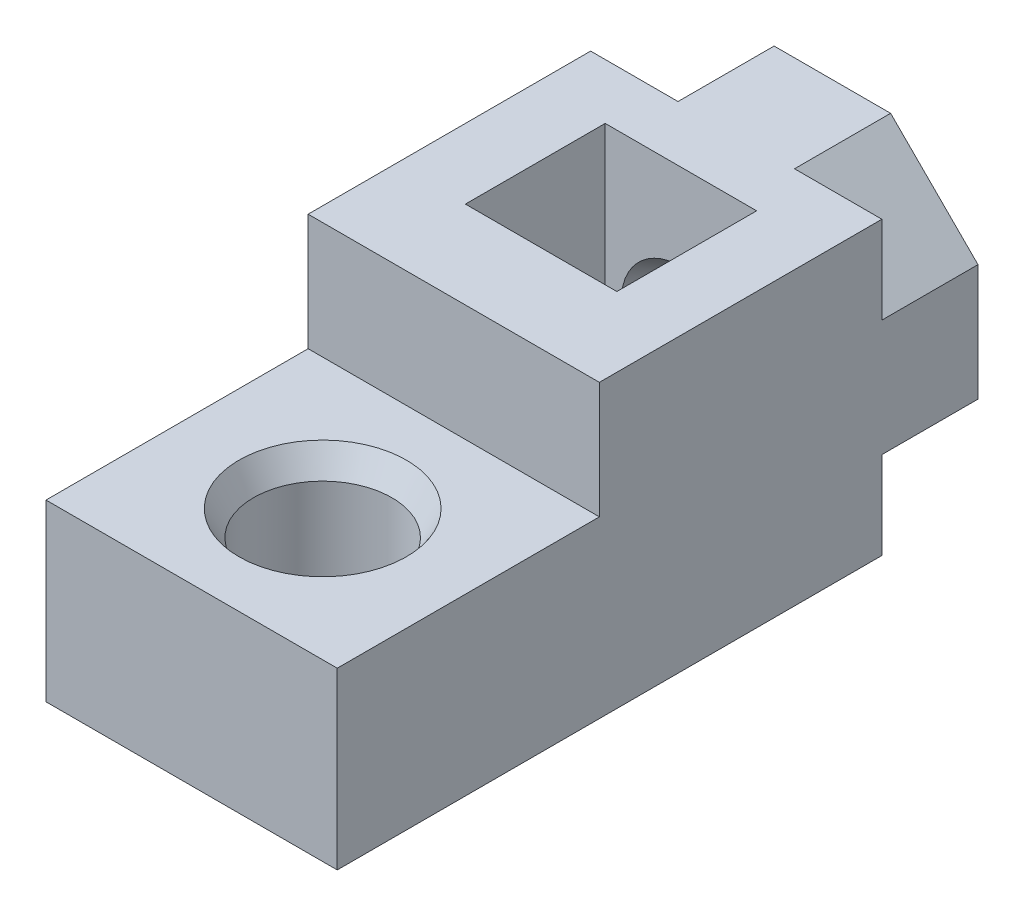
from build123d import *

# Parameters (mm, degrees)
SKETCH_1_W             = 10
SKETCH_1_H             = 10
EXTRUDE_1_DEPTH        = 22
CUT_EXTRUDE_START      = -5.2
CUT_EXTRUDE_10_DEPTH   = 4.8
SKETCH_14_R            = 1.55
CUT_EXTRUDE_11_DEPTH   = 10
SKETCH_15_W            = 10
SKETCH_15_H            = 9
CUT_EXTRUDE_12_DEPTH   = 4
SKETCH_16_R            = 2.375
CUT_EXTRUDE_13_DEPTH   = 7
CUT_EXTRUDE_14_DEPTH   = 3.3
CHAMFER_1_SIZE         = 0.5
CHAMFER_1_SIZE2        = 0.866025404
CHAMFER_1_PART_2_SIZE  = 0.5
CHAMFER_1_PART_2_SIZE2 = 0.866025404
CHAMFER_1_PART_3_SIZE  = 0.5
CHAMFER_1_PART_3_SIZE2 = 0.866025404
CHAMFER_1_PART_4_SIZE  = 0.5
CHAMFER_1_PART_4_SIZE2 = 0.866025404


with BuildPart() as part:
    # 草图1 → 凸台-拉伸1 (new body)
    with BuildSketch(Plane.XY):
        Rectangle(SKETCH_1_W, SKETCH_1_H)
    extrude(amount=EXTRUDE_1_DEPTH)

    # 草图13 → 切除-拉伸10 (cut)
    with BuildSketch(Plane(origin=(0, 0, 0), x_dir=(-1, 0, 0), z_dir=(0, 0, -1)).offset(CUT_EXTRUDE_START)):
        Polygon((2.6, 1.823001189), (2.6, 6), (-2.6, 6), (-2.6, 1.654219648), (-2.6, -1.5011107), (0, -3.0022214), (2.6, -1.5011107), align=None)
    extrude(amount=-CUT_EXTRUDE_10_DEPTH, mode=Mode.SUBTRACT)

    # 草图14 → 切除-拉伸11 (cut)
    with BuildSketch(Plane(origin=(0, 0, 0), x_dir=(-1, 0, 0), z_dir=(0, 0, -1))):
        Circle(SKETCH_14_R)
    extrude(amount=-CUT_EXTRUDE_11_DEPTH, mode=Mode.SUBTRACT)

    # 草图15 → 切除-拉伸12 (cut)
    with BuildSketch(Plane(origin=(0, 5, 0), x_dir=(1, 0, 0), z_dir=(0, 1, 0))):
        with Locations((0, -17.5)):
            Rectangle(SKETCH_15_W, SKETCH_15_H)
    extrude(amount=-CUT_EXTRUDE_12_DEPTH, mode=Mode.SUBTRACT)

    # 草图16 → 切除-拉伸13 (cut, through all)
    with BuildSketch(Plane(origin=(0, 1, 0), x_dir=(1, 0, 0), z_dir=(0, 1, 0))):
        with Locations((0, -17.5)):
            Circle(SKETCH_16_R)
    extrude(amount=-CUT_EXTRUDE_13_DEPTH, mode=Mode.SUBTRACT)

    # 草图17 → 切除-拉伸14 (cut)
    with BuildSketch(Plane(origin=(0, 0, 0), x_dir=(-1, 0, 0), z_dir=(0, 0, -1))):
        Polygon((5, 5), (2, 5), (5, 2), align=None)
        Polygon((5, -5), (5, -2), (2, -5), align=None)
        Polygon((-5, 5), (-5, 2), (-2, 5), align=None)
        Polygon((-5, -5), (-2, -5), (-5, -2), align=None)
    extrude(amount=-CUT_EXTRUDE_14_DEPTH, mode=Mode.SUBTRACT)

    # 倒角1
    chamfer_1_edges = [part.edges().sort_by_distance(p)[0] for p in [
        (1.55, 0, 5.2),
    ]]
    chamfer_1_side = [part.faces().sort_by_distance(p)[0] for p in [
        (0, 1.701860009, 5.2),
    ]]
    chamfer(chamfer_1_edges, length=CHAMFER_1_SIZE, length2=CHAMFER_1_SIZE2, reference=chamfer_1_side[0])

    # 倒角1 part 2
    chamfer_1_part_2_edges = [part.edges().sort_by_distance(p)[0] for p in [
        (1.55, 0, 0),
    ]]
    chamfer_1_part_2_side = [part.faces().sort_by_distance(p)[0] for p in [
        (-3.4, 3.4, 0),
    ]]
    chamfer(chamfer_1_part_2_edges, length=CHAMFER_1_PART_2_SIZE, length2=CHAMFER_1_PART_2_SIZE2, reference=chamfer_1_part_2_side[0])

    # 倒角1 part 3
    chamfer_1_part_3_edges = [part.edges().sort_by_distance(p)[0] for p in [
        (-2.375, -5, 17.5),
    ]]
    chamfer_1_part_3_side = [part.faces().sort_by_distance(p)[0] for p in [
        (0, -5, 11.383311376),
    ]]
    chamfer(chamfer_1_part_3_edges, length=CHAMFER_1_PART_3_SIZE, length2=CHAMFER_1_PART_3_SIZE2, reference=chamfer_1_part_3_side[0])

    # 倒角1 part 4
    chamfer_1_part_4_edges = [part.edges().sort_by_distance(p)[0] for p in [
        (-2.375, 1, 17.5),
    ]]
    chamfer_1_part_4_side = [part.faces().sort_by_distance(p)[0] for p in [
        (0, 1, 21.86546376),
    ]]
    chamfer(chamfer_1_part_4_edges, length=CHAMFER_1_PART_4_SIZE, length2=CHAMFER_1_PART_4_SIZE2, reference=chamfer_1_part_4_side[0])


solid = part.part
